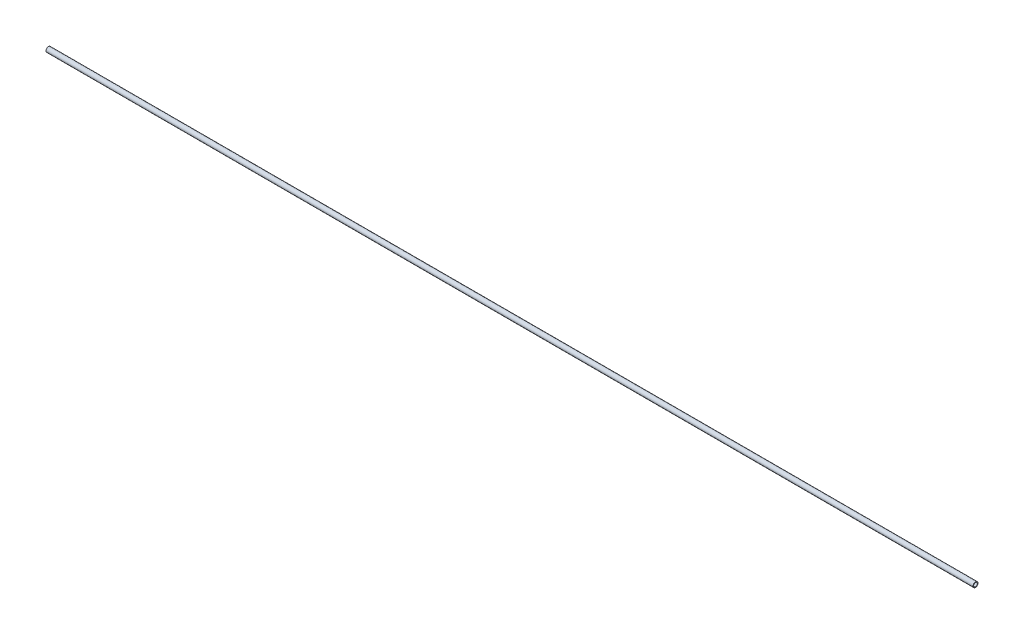
from build123d import *

# Parameters (mm, degrees)
CROQUIS1_R              = 8.35
CROQUIS1_R_2            = 6.35
SALIENTE_EXTRUIR1_DEPTH = 1570


with BuildPart() as part:
    # Croquis1 → Saliente-Extruir1 (new body, symmetric)
    with BuildSketch(Plane(origin=(0, 0, 0), x_dir=(0, 0, -1), z_dir=(1, 0, 0))):
        Circle(CROQUIS1_R)
        Circle(CROQUIS1_R_2, mode=Mode.SUBTRACT)
    extrude(amount=SALIENTE_EXTRUIR1_DEPTH, both=True)


solid = part.part
